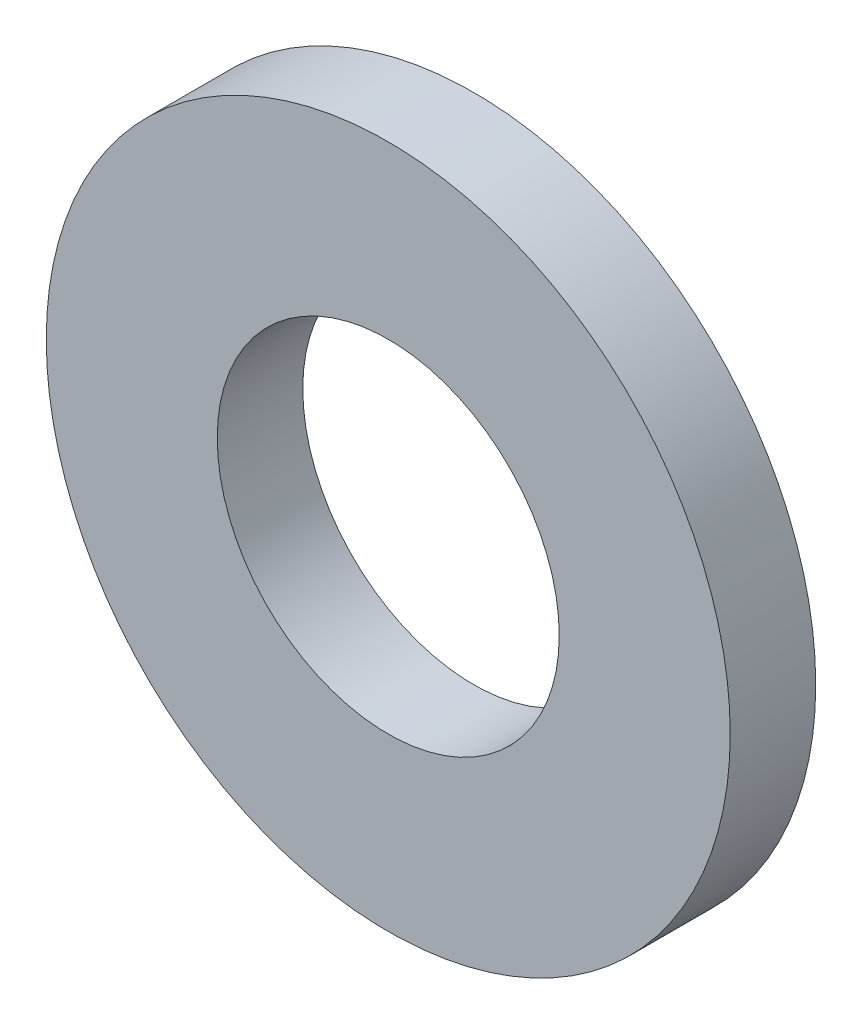
from build123d import *

# Parameters (mm, degrees)
SKETCH2_R           = 8
SKETCH2_R_2         = 4
BOSS_EXTRUDE1_DEPTH = 2


with BuildPart() as part:
    # Sketch2 → Boss-Extrude1 (new body)
    with BuildSketch(Plane.XY):
        Circle(SKETCH2_R)
        Circle(SKETCH2_R_2, mode=Mode.SUBTRACT)
    extrude(amount=BOSS_EXTRUDE1_DEPTH)


solid = part.part
